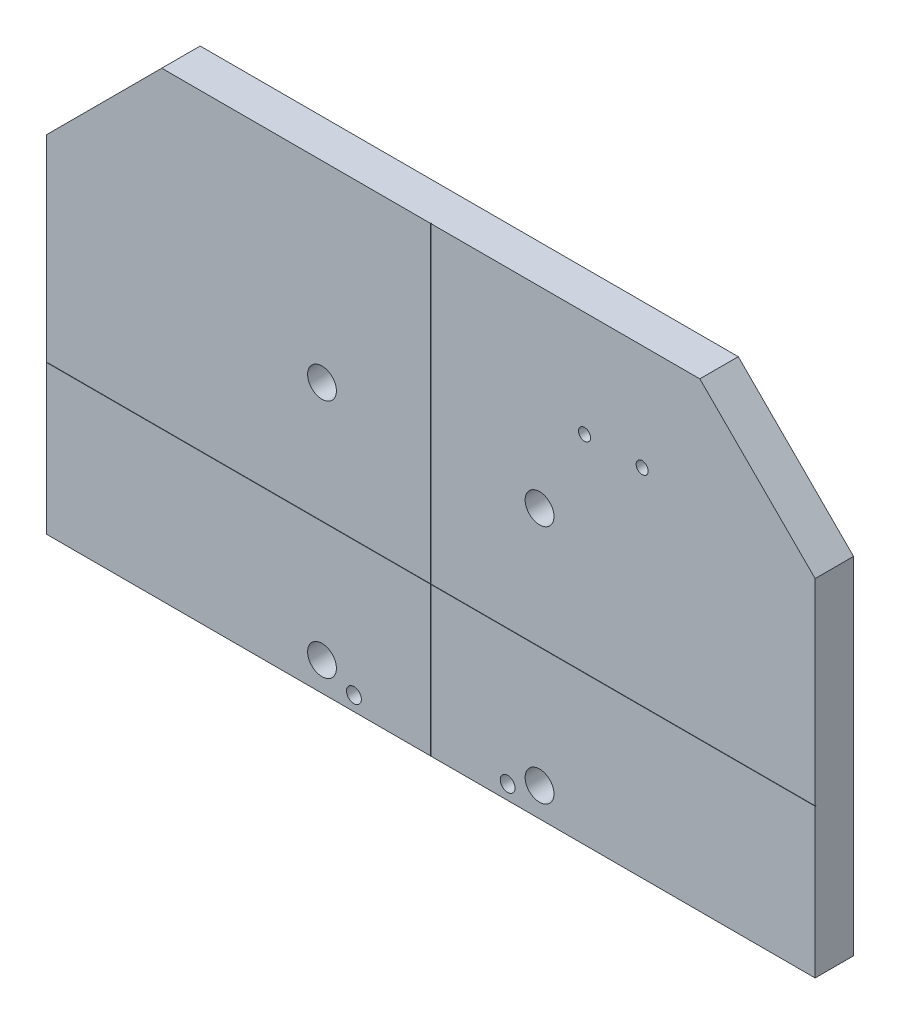
from build123d import *

# Parameters (mm, degrees)
BOSS_EXTRUDE1_DEPTH     = 25.4
CUT_EXTRUDE1_DEPTH      = 305.8
CUT_EXTRUDE2_DEPTH      = 509.0000001
SKETCH4_R               = 3.9751
SKETCH4_R_2             = 4.9022
CUT_EXTRUDE5_DEPTH      = 26.4000001
CUT_EXTRUDE5_DEPTH_BACK = 25.4
SKETCH7_R               = 9.525
CUT_EXTRUDE6_DEPTH      = 26.4000001


with BuildPart() as part:
    # Sketch1 → Boss-Extrude1 (new body)
    with BuildSketch(Plane.XY):
        Polygon((-281.238157895, 20.804605263), (-281.238157895, -207.795394737), (226.761842105, -207.795394737), (226.761842105, 20.804605263), (150.561842105, 97.004605263), (-205.038157895, 97.004605263), align=None)
    extrude(amount=BOSS_EXTRUDE1_DEPTH)

    # Sketch2 → Cut-Extrude1 (cut, through all)
    with BuildSketch(Plane(origin=(0, 97.004605263, 0), x_dir=(1, 0, 0), z_dir=(0, 1, 0))):
        with BuildLine():
            Line((-27.365157895, -25.4), (-27.111157895, -25.4))
            add(Edge.make_bspline(
                [(-27.365157895, -25.4), (-27.238157895, -23.876), (-27.111157895, -25.4)],
                knots=[0, 0, 0, 1, 1, 1], degree=2))
        make_face()
    extrude(amount=-CUT_EXTRUDE1_DEPTH, mode=Mode.SUBTRACT)

    # Sketch3 → Cut-Extrude2 (cut, through all)
    with BuildSketch(Plane(origin=(226.761842105, 0, 0), x_dir=(0, 0, -1), z_dir=(1, 0, 0))):
        with BuildLine():
            Line((-25.4, -109.243394737), (-25.4, -109.497394737))
            add(Edge.make_bspline(
                [(-25.4, -109.243394737), (-23.876, -109.370394737), (-25.4, -109.497394737)],
                knots=[0, 0, 0, 1, 1, 1], degree=2))
        make_face()
    extrude(amount=-CUT_EXTRUDE2_DEPTH, mode=Mode.SUBTRACT)

    # Sketch4 → Cut-Extrude5 (cut, two sides)
    with BuildSketch(Plane.XY) as cut_extrude5_sk:
        with Locations((74.361842105, 27.154605263)):
            Circle(SKETCH4_R)
        with Locations((112.461842105, 27.154605263)):
            Circle(SKETCH4_R)
        with Locations((23.561842105, -198.270394737)):
            Circle(SKETCH4_R_2)
        with Locations((-78.038157895, -198.270394737)):
            Circle(SKETCH4_R_2)
    extrude(amount=CUT_EXTRUDE5_DEPTH, mode=Mode.SUBTRACT)
    extrude(cut_extrude5_sk.sketch, amount=-CUT_EXTRUDE5_DEPTH_BACK, mode=Mode.SUBTRACT)

    # Sketch7 → Cut-Extrude6 (cut, through all)
    with BuildSketch(Plane(origin=(0, 0, 0), x_dir=(-1, 0, 0), z_dir=(0, 0, -1))):
        with Locations((99.120157895, -29.995394737)):
            Circle(SKETCH7_R)
        with Locations((-44.643842105, -29.995394737)):
            Circle(SKETCH7_R)
        with Locations((-44.643842105, -188.745394737)):
            Circle(SKETCH7_R)
        with Locations((99.120157895, -188.745394737)):
            Circle(SKETCH7_R)
    extrude(amount=-CUT_EXTRUDE6_DEPTH, mode=Mode.SUBTRACT)


solid = part.part
